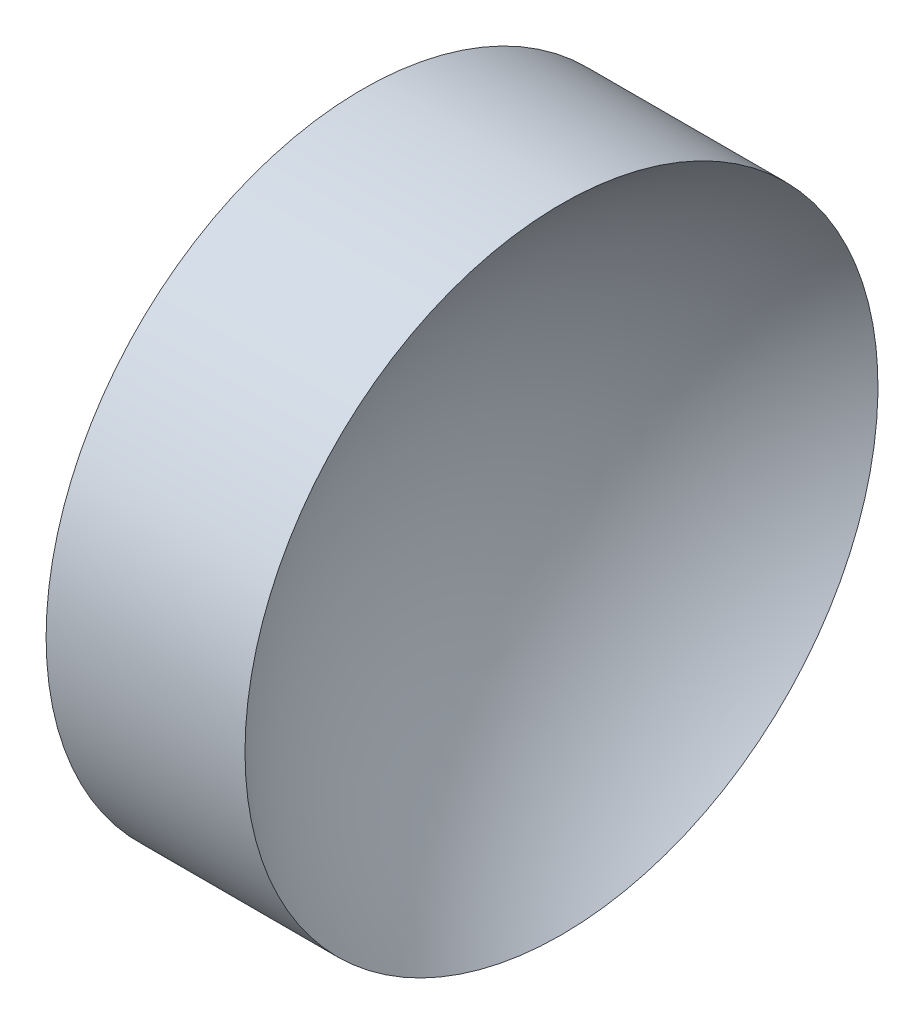
from build123d import *


with BuildPart() as part:
    # 草图1 → 旋转1 (revolve)
    with BuildSketch(Plane.XY, mode=Mode.PRIVATE) as revolve_1_sk:
        with BuildLine():
            Line((57.532337053, 32.610768129), (57.532337053, 45.110768129))
            Line((57.532337053, 45.110768129), (65.387784734, 45.110768129))
            ThreePointArc((65.387784734, 45.110768129), (61.068741663, 39.512511886), (59.532337053, 32.610768129))
            Line((59.532337053, 32.610768129), (57.532337053, 32.610768129))
        make_face()
    revolve(revolve_1_sk.sketch.rotate(Axis((56.10091508, 32.610768129, 0), (1, 0, 0)), 180), axis=Axis((56.10091508, 32.610768129, 0), (1, 0, 0)))  # turned: the seam where the file's is


solid = part.part
